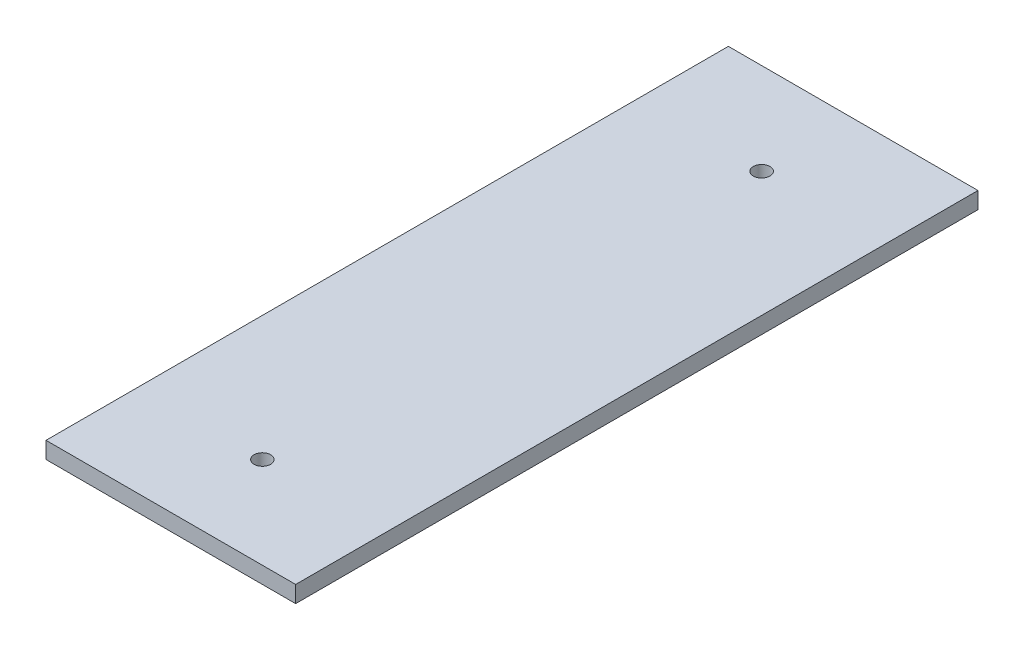
from build123d import *

# Parameters (mm, degrees)
ESBO_O1_W                = 30
ESBO_O1_H                = 82
RESSALTO_EXTRUS_O1_DEPTH = 2
ESBO_O2_R                = 1
CORTE_EXTRUS_O1_DEPTH    = 3


with BuildPart() as part:
    # Esboço1 → Ressalto-extrusão1 (new body)
    with BuildSketch(Plane(origin=(0, 0, 0), x_dir=(1, 0, 0), z_dir=(0, 1, 0))):
        with Locations((15, 41)):
            Rectangle(ESBO_O1_W, ESBO_O1_H)
    extrude(amount=RESSALTO_EXTRUS_O1_DEPTH)

    # Esboço2 → Corte-extrusão1 (cut, through all)
    with BuildSketch(Plane(origin=(0, 2, 0), x_dir=(1, 0, 0), z_dir=(0, 1, 0))):
        with Locations((15, 71)):
            Circle(ESBO_O2_R)
        with Locations((15, 11)):
            Circle(ESBO_O2_R)
    extrude(amount=-CORTE_EXTRUS_O1_DEPTH, mode=Mode.SUBTRACT)


solid = part.part
